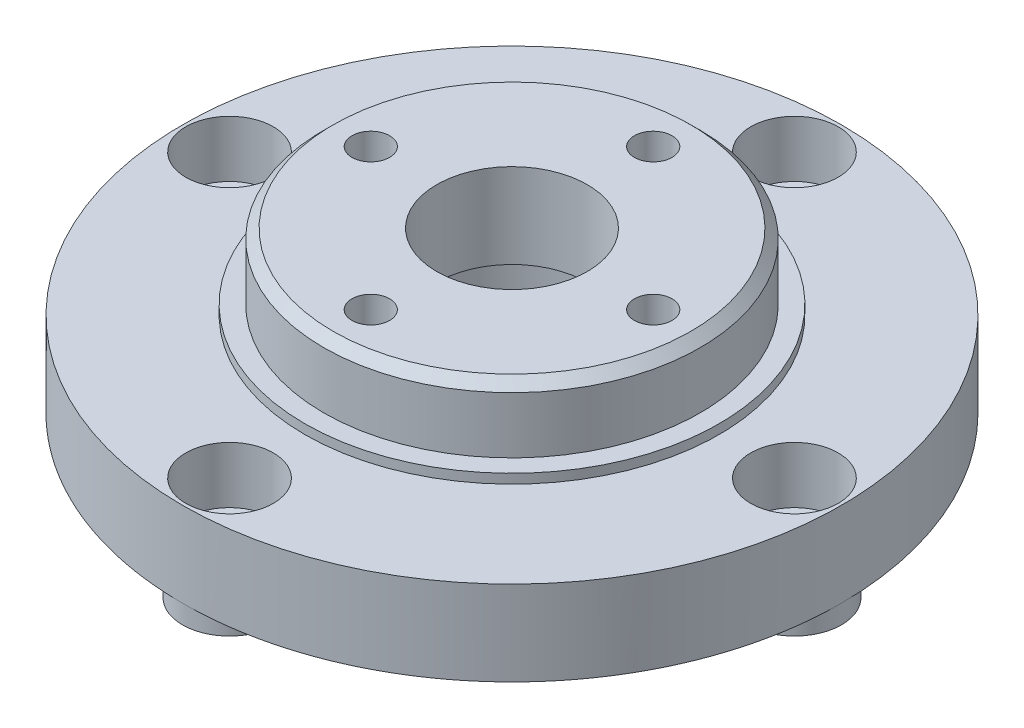
from build123d import *

# Parameters (mm, degrees)
SKETCH1_R           = 35
SKETCH1_R_2         = 11.1
SKETCH1_R_3         = 2.65
BOSS_EXTRUDE1_DEPTH = 3
SKETCH2_R           = 35
SKETCH2_R_2         = 4.65
SKETCH2_R_3         = 11.1
BOSS_EXTRUDE2_DEPTH = 6
SKETCH3_R           = 11.1
SKETCH3_R_2         = 8
BOSS_EXTRUDE3_DEPTH = 1
SKETCH4_R           = 20
SKETCH4_R_2         = 8
BOSS_EXTRUDE4_DEPTH = 8
SKETCH5_R           = 22
SKETCH5_R_2         = 20
BOSS_EXTRUDE5_DEPTH = 1
SKETCH6_R           = 5
SKETCH6_R_2         = 2.65
BOSS_EXTRUDE6_DEPTH = 2
SKETCH7_R           = 2
CUT_EXTRUDE1_DEPTH  = 20
CHAMFER1_SIZE       = 1


with BuildPart() as part:
    # Sketch1 → Boss-Extrude1 (new body)
    with BuildSketch(Plane(origin=(0, 0, 0), x_dir=(1, 0, 0), z_dir=(0, 1, 0))):
        Circle(SKETCH1_R)
        Circle(SKETCH1_R_2, mode=Mode.SUBTRACT)
        with Locations((0, 30)):
            Circle(SKETCH1_R_3, mode=Mode.SUBTRACT)
        with Locations((30, 0)):
            Circle(SKETCH1_R_3, mode=Mode.SUBTRACT)
        with Locations((0, -30)):
            Circle(SKETCH1_R_3, mode=Mode.SUBTRACT)
        with Locations((-30, 0)):
            Circle(SKETCH1_R_3, mode=Mode.SUBTRACT)
    extrude(amount=BOSS_EXTRUDE1_DEPTH)

    # Sketch2 → Boss-Extrude2 (add)
    with BuildSketch(Plane(origin=(0, 3, 0), x_dir=(1, 0, 0), z_dir=(0, 1, 0))):
        Circle(SKETCH2_R)
        with Locations((0, -30)):
            Circle(SKETCH2_R_2, mode=Mode.SUBTRACT)
        with Locations((30, 0)):
            Circle(SKETCH2_R_2, mode=Mode.SUBTRACT)
        with Locations((0, 30)):
            Circle(SKETCH2_R_2, mode=Mode.SUBTRACT)
        with Locations((-30, 0)):
            Circle(SKETCH2_R_2, mode=Mode.SUBTRACT)
        Circle(SKETCH2_R_3, mode=Mode.SUBTRACT)
    extrude(amount=BOSS_EXTRUDE2_DEPTH)

    # Sketch3 → Boss-Extrude3 (add)
    with BuildSketch(Plane(origin=(0, 9, 0), x_dir=(1, 0, 0), z_dir=(0, 1, 0))):
        Circle(SKETCH3_R)
        Circle(SKETCH3_R_2, mode=Mode.SUBTRACT)
    extrude(amount=-BOSS_EXTRUDE3_DEPTH)

    # Sketch4 → Boss-Extrude4 (add)
    with BuildSketch(Plane(origin=(0, 9, 0), x_dir=(1, 0, 0), z_dir=(0, 1, 0))):
        Circle(SKETCH4_R)
        Circle(SKETCH4_R_2, mode=Mode.SUBTRACT)
    extrude(amount=BOSS_EXTRUDE4_DEPTH)

    # Sketch5 → Boss-Extrude5 (add)
    with BuildSketch(Plane(origin=(0, 9, 0), x_dir=(1, 0, 0), z_dir=(0, 1, 0))):
        Circle(SKETCH5_R)
        Circle(SKETCH5_R_2, mode=Mode.SUBTRACT)
    extrude(amount=BOSS_EXTRUDE5_DEPTH)

    # Sketch6 → Boss-Extrude6 (add)
    with BuildSketch(Plane(origin=(0, 0, 0), x_dir=(-1, 0, 0), z_dir=(0, -1, 0))):
        with Locations((30, 0)):
            Circle(SKETCH6_R)
        with Locations((30, 0)):
            Circle(SKETCH6_R_2, mode=Mode.SUBTRACT)
        with Locations((0, -30)):
            Circle(SKETCH6_R)
        with Locations((0, -30)):
            Circle(SKETCH6_R_2, mode=Mode.SUBTRACT)
        with Locations((-30, 0)):
            Circle(SKETCH6_R)
        with Locations((-30, 0)):
            Circle(SKETCH6_R_2, mode=Mode.SUBTRACT)
        with Locations((0, 30)):
            Circle(SKETCH6_R)
        with Locations((0, 30)):
            Circle(SKETCH6_R_2, mode=Mode.SUBTRACT)
    extrude(amount=BOSS_EXTRUDE6_DEPTH)

    # Sketch7 → Cut-Extrude1 (cut, through all)
    with BuildSketch(Plane(origin=(0, 17, 0), x_dir=(1, 0, 0), z_dir=(0, 1, 0))):
        with Locations((0, 15)):
            Circle(SKETCH7_R)
        with Locations((15, 0)):
            Circle(SKETCH7_R)
        with Locations((0, -15)):
            Circle(SKETCH7_R)
        with Locations((-15, 0)):
            Circle(SKETCH7_R)
    extrude(amount=-CUT_EXTRUDE1_DEPTH, mode=Mode.SUBTRACT)

    # Chamfer1
    chamfer1_edges = [part.edges().sort_by_distance(p)[0] for p in [
        (-11.1, 0, 0),
        (-20, 17, 0),
    ]]
    chamfer(chamfer1_edges, length=CHAMFER1_SIZE)


solid = part.part
